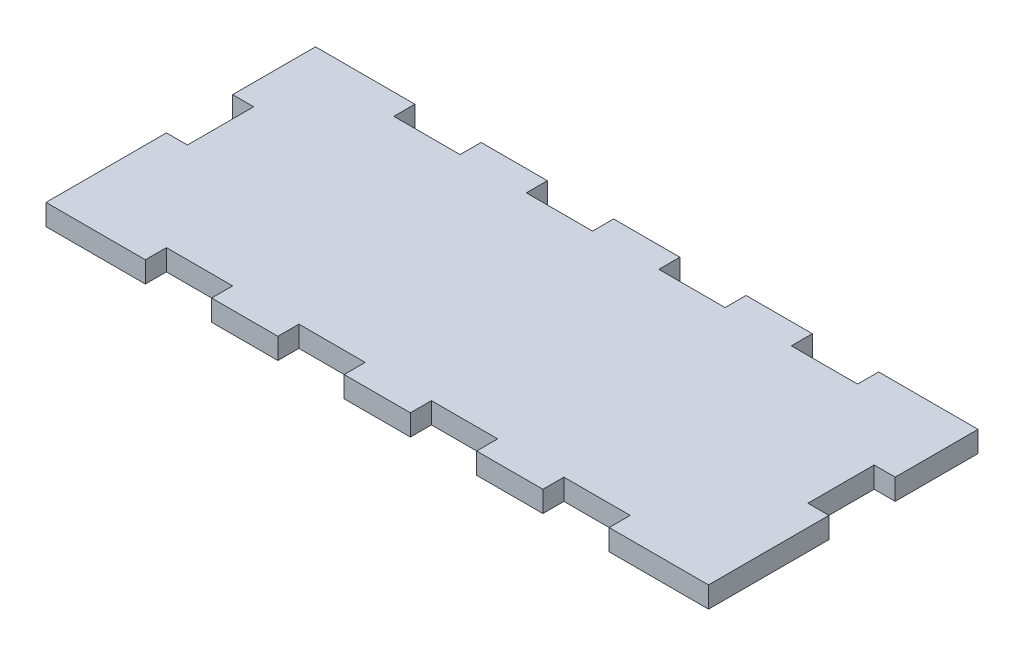
from build123d import *

# Parameters (mm, degrees)
SKETCH1_W           = 30
SKETCH1_H           = 6.35
SKETCH1_W_2         = 20
BOSS_EXTRUDE1_DEPTH = 6.35


with BuildPart() as part:
    # Sketch1 → Boss-Extrude1 (new body)
    with BuildSketch(Plane(origin=(0, 0, 0), x_dir=(1, 0, 0), z_dir=(0, 1, 0))):
        Polygon((0, 30), (0, 0), (30, 0), (50, 0), (70, 0), (90, 0), (110, 0), (130, 0), (150, 0), (170, 0), (200, 0), (200, 30), (193.65, 30), (193.65, 50), (200, 50), (200, 75), (170, 75), (170, 68.65), (150, 68.65), (150, 75), (130, 75), (130, 68.65), (110, 68.65), (110, 75), (90, 75), (90, 68.65), (70, 68.65), (70, 75), (50, 75), (50, 68.65), (30, 68.65), (30, 75), (0, 75), (0, 50), (6.35, 50), (6.35, 30), align=None)
        with Locations((15, -3.175)):
            Rectangle(SKETCH1_W, SKETCH1_H)
        with Locations((60, -3.175)):
            Rectangle(SKETCH1_W_2, SKETCH1_H)
        with Locations((100, -3.175)):
            Rectangle(SKETCH1_W_2, SKETCH1_H)
        with Locations((140, -3.175)):
            Rectangle(SKETCH1_W_2, SKETCH1_H)
        with Locations((185, -3.175)):
            Rectangle(SKETCH1_W, SKETCH1_H)
    extrude(amount=BOSS_EXTRUDE1_DEPTH)


solid = part.part
